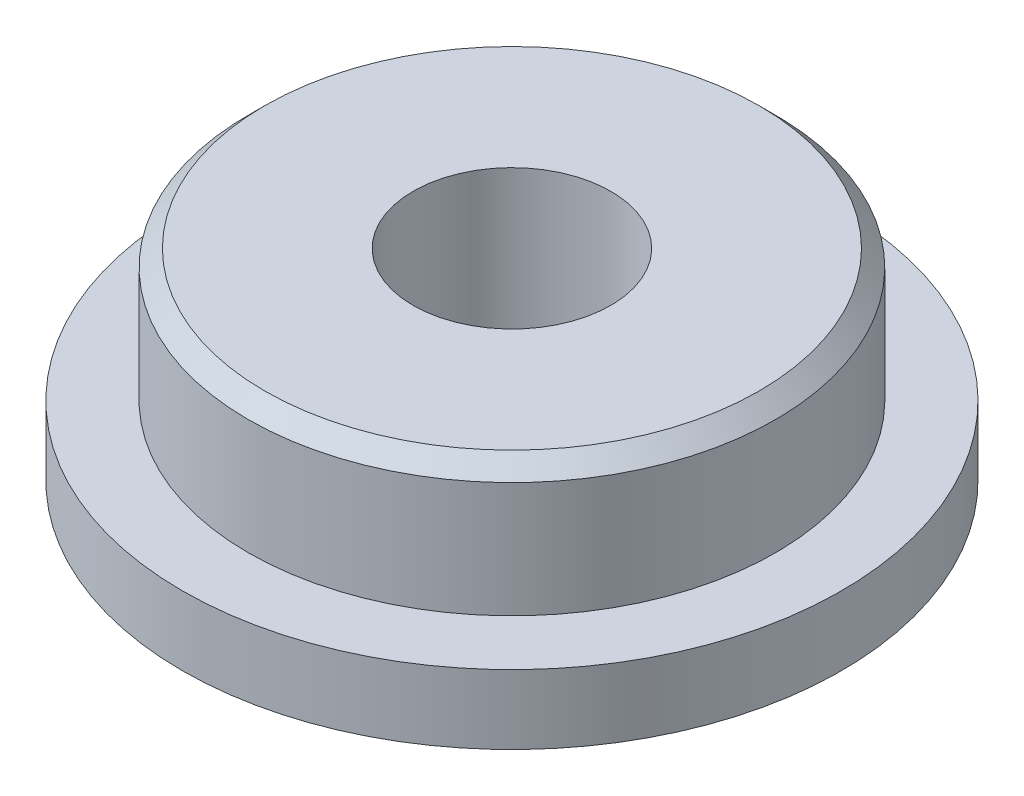
from build123d import *

# Parameters (mm, degrees)
SKETCH1_R           = 5
BOSS_EXTRUDE1_DEPTH = 1.05
SKETCH2_R           = 4
BOSS_EXTRUDE2_DEPTH = 2
SKETCH3_R           = 1.5
CUT_EXTRUDE1_DEPTH  = 12
CHAMFER2_SIZE       = 0.25


with BuildPart() as part:
    # Sketch1 → Boss-Extrude1 (new body)
    with BuildSketch(Plane(origin=(0, 0, 0), x_dir=(1, 0, 0), z_dir=(0, 1, 0))):
        Circle(SKETCH1_R)
    extrude(amount=BOSS_EXTRUDE1_DEPTH)

    # Sketch2 → Boss-Extrude2 (add)
    with BuildSketch(Plane(origin=(0, 1.05, 0), x_dir=(1, 0, 0), z_dir=(0, 1, 0))):
        Circle(SKETCH2_R)
    extrude(amount=BOSS_EXTRUDE2_DEPTH)

    # Sketch3 → Cut-Extrude1 (cut)
    with BuildSketch(Plane(origin=(0, 3.05, 0), x_dir=(1, 0, 0), z_dir=(0, 1, 0))):
        Circle(SKETCH3_R)
    extrude(amount=-CUT_EXTRUDE1_DEPTH, mode=Mode.SUBTRACT)

    # Chamfer2
    chamfer2_edges = [part.edges().sort_by_distance(p)[0] for p in [
        (-4, 3.05, 0),
    ]]
    chamfer(chamfer2_edges, length=CHAMFER2_SIZE)


solid = part.part
